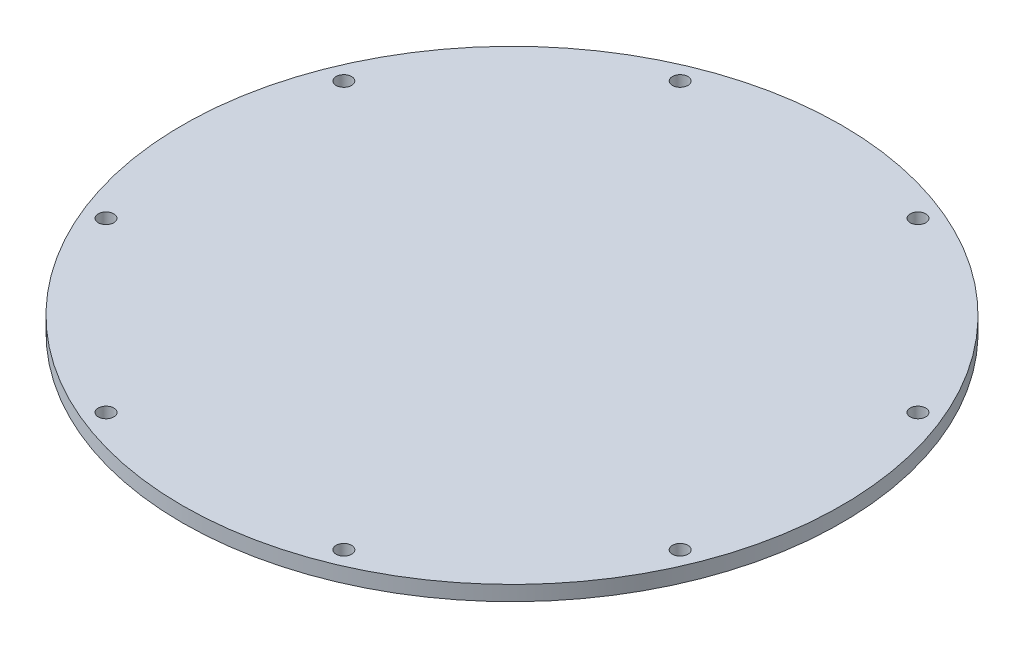
from build123d import *

# Parameters (mm, degrees)
BASE_W_MOTOR_MOUNTS_R  = 70
BOSS_EXTRUDE1_DEPTH    = 3.175
STANDOFFS_TOP_BOTTOM_R = 1.65
CUT_EXTRUDE2_DEPTH     = 3.175


with BuildPart() as part:
    # Base w/ Motor Mounts → Boss-Extrude1 (new body)
    with BuildSketch(Plane(origin=(0, 0, 0), x_dir=(1, 0, 0), z_dir=(0, 1, 0))):
        Circle(BASE_W_MOTOR_MOUNTS_R)
    extrude(amount=BOSS_EXTRUDE1_DEPTH)

    # Standoffs (top / bottom) → Cut-Extrude2 (cut)
    with BuildSketch(Plane(origin=(0, 0, 0), x_dir=(1, 0, 0), z_dir=(0, 1, 0))):
        with Locations((25.257106536, 60.976049146)):
            Circle(STANDOFFS_TOP_BOTTOM_R)
        with Locations((60.976049146, 25.257106536)):
            Circle(STANDOFFS_TOP_BOTTOM_R)
        with Locations((60.976049146, -25.257106536)):
            Circle(STANDOFFS_TOP_BOTTOM_R)
        with Locations((25.257106536, -60.976049146)):
            Circle(STANDOFFS_TOP_BOTTOM_R)
        with Locations((-25.257106536, -60.976049146)):
            Circle(STANDOFFS_TOP_BOTTOM_R)
        with Locations((-60.976049146, -25.257106536)):
            Circle(STANDOFFS_TOP_BOTTOM_R)
        with Locations((-60.976049146, 25.257106536)):
            Circle(STANDOFFS_TOP_BOTTOM_R)
        with Locations((-25.257106536, 60.976049146)):
            Circle(STANDOFFS_TOP_BOTTOM_R)
    extrude(amount=CUT_EXTRUDE2_DEPTH, mode=Mode.SUBTRACT)


solid = part.part
